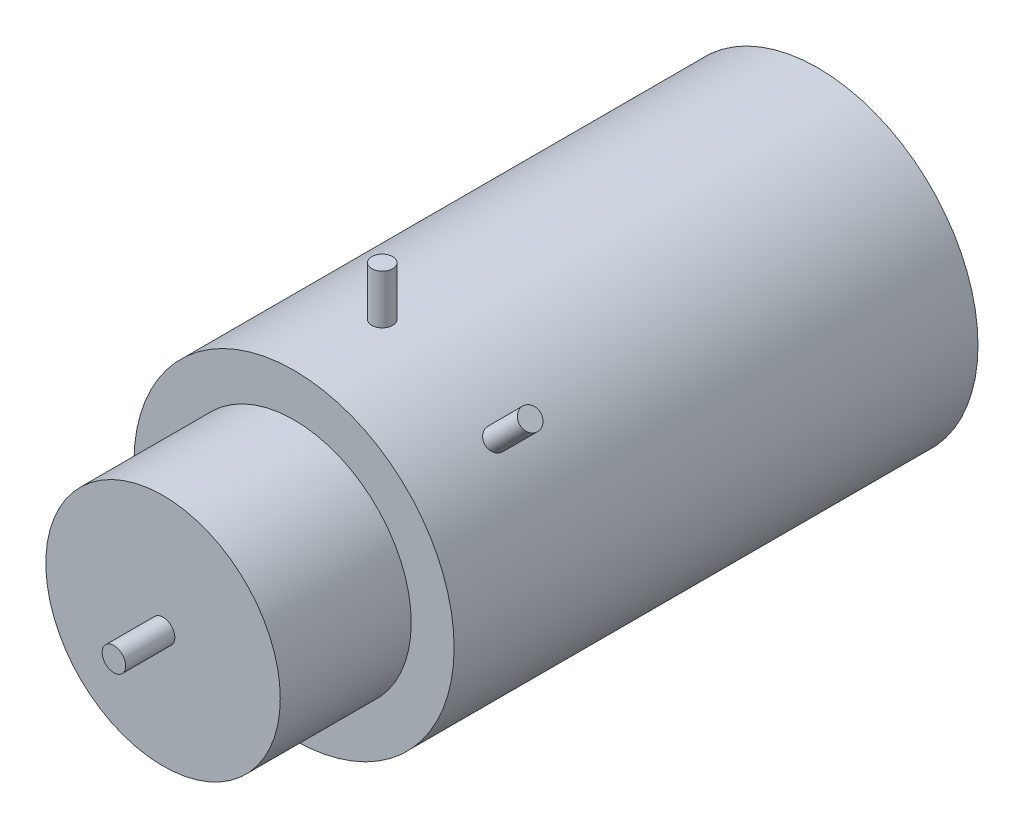
from build123d import *

# Parameters (mm, degrees)
SKETCH1_R           = 31.0515
BOSS_EXTRUDE1_DEPTH = 101.6
SKETCH2_R           = 22.733
BOSS_EXTRUDE2_DEPTH = 25.4
SKETCH3_R           = 2.286
BOSS_EXTRUDE3_DEPTH = 9.525
SKETCH4_R           = 2.032
BOSS_EXTRUDE4_DEPTH = 9.525
CIRPATTERN3_COUNT   = 2
CIRPATTERN3_ANGLE   = 45


with BuildPart() as part:
    # Sketch1 → Boss-Extrude1 (new body)
    with BuildSketch(Plane.XY):
        Circle(SKETCH1_R)
    extrude(amount=BOSS_EXTRUDE1_DEPTH)

    # Sketch2 → Boss-Extrude2 (add)
    with BuildSketch(Plane.XY.offset(101.6)):
        Circle(SKETCH2_R)
    extrude(amount=BOSS_EXTRUDE2_DEPTH)

    # Sketch3 → Boss-Extrude3 (add)
    with BuildSketch(Plane.XY.offset(127)):
        Circle(SKETCH3_R)
    extrude(amount=BOSS_EXTRUDE3_DEPTH)


with BuildPart() as body_2:
    # Sketch4 → Boss-Extrude4 (new body)
    with BuildSketch(Plane(origin=(0, 31.0515, 0), x_dir=(1, 0, 0), z_dir=(0, 1, 0))):
        with Locations((0, -84.487378835)):
            Circle(SKETCH4_R)
    extrude(amount=BOSS_EXTRUDE4_DEPTH)


with BuildPart() as cirpattern3_1:
    # CirPattern3: pattern copy
    add(body_2.part.rotate(Axis((0, 0, 143.35125), (0, 0, -1)), 1 * CIRPATTERN3_ANGLE / (CIRPATTERN3_COUNT - 1)))


solid = Compound([part.part, body_2.part, cirpattern3_1.part])
